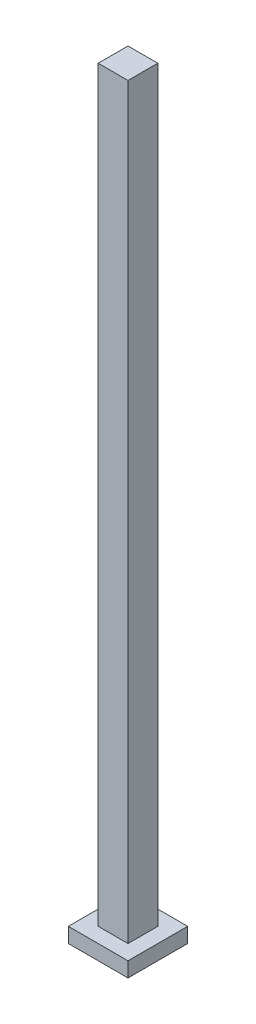
from build123d import *

# Parameters (mm, degrees)
ESTRUSIONE_ESTRUSIONE1_DEPTH = 100
SCHIZZO2_W                   = 100
SCHIZZO2_H                   = 100
SCHIZZO2_W_2                 = 90
SCHIZZO2_H_2                 = 90
ESTRUSIONE_ESTRUSIONE2_DEPTH = 2500
SCHIZZO3_W                   = 100
SCHIZZO3_H                   = 100
ESTRUSIONE_ESTRUSIONE3_DEPTH = 5


with BuildPart() as part:
    # Schizzo1 → Estrusione-Estrusione1 (new body, symmetric)
    with BuildSketch(Plane.XY):
        Polygon((0, 0), (100, 0), (100, 50), (-100, 50), (-100, 0), align=None)
    extrude(amount=ESTRUSIONE_ESTRUSIONE1_DEPTH, both=True)

    # Schizzo2 → Estrusione-Estrusione2 (add)
    with BuildSketch(Plane(origin=(0, 50, 0), x_dir=(1, 0, 0), z_dir=(0, 1, 0))):
        Rectangle(SCHIZZO2_W, SCHIZZO2_H)
        with Locations((-0.272675023, -0.401025499)):
            Rectangle(SCHIZZO2_W_2, SCHIZZO2_H_2, mode=Mode.SUBTRACT)
    extrude(amount=ESTRUSIONE_ESTRUSIONE2_DEPTH)

    # Schizzo3 → Estrusione-Estrusione3 (add)
    with BuildSketch(Plane(origin=(0, 2550, 0), x_dir=(1, 0, 0), z_dir=(0, 1, 0))):
        Rectangle(SCHIZZO3_W, SCHIZZO3_H)
    extrude(amount=ESTRUSIONE_ESTRUSIONE3_DEPTH)


solid = part.part
